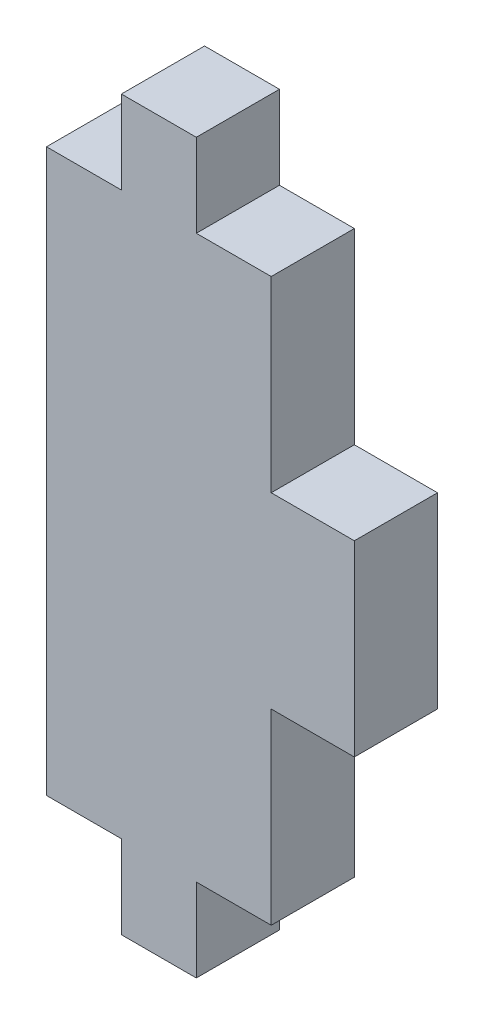
from build123d import *

# Parameters (mm, degrees)
BOSS_EXTRUDE1_DEPTH = 4.699


with BuildPart() as part:
    # Sketch1 → Boss-Extrude1 (new body)
    with BuildSketch(Plane.XY):
        Polygon((8.466666667, 31.75), (12.7, 31.75), (12.7, 21.166666667), (17.399, 21.166666667), (17.399, 10.583333333), (12.7, 10.583333333), (12.7, 0), (8.466666667, 0), (8.466666667, -4.699), (4.233333333, -4.699), (4.233333333, 0), (0, 0), (0, 31.75), (4.233333333, 31.75), (4.233333333, 36.449), (8.466666667, 36.449), align=None)
    extrude(amount=BOSS_EXTRUDE1_DEPTH)


solid = part.part
